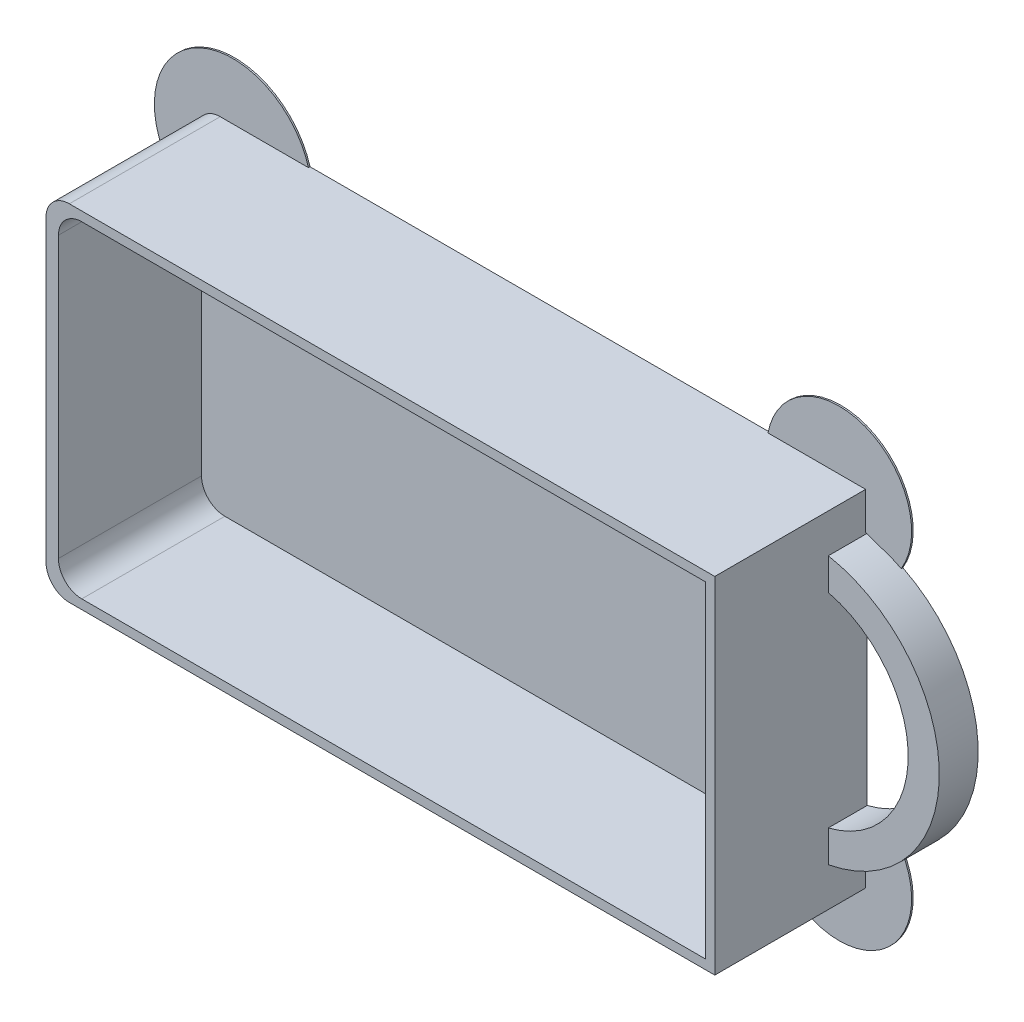
from build123d import *

# Parameters (mm, degrees)
SKETCH_1_W          = 86
SKETCH_1_H          = 44.4
EXTRUDE_1_DEPTH     = 19.6
EXTRUDE_2_DEPTH     = 5
SKETCH_3_W          = 83.2
SKETCH_3_H          = 42
CUT_EXTRUDE_1_DEPTH = 18.4
FILLET_1_R          = 3
EXTRUDE_3_DEPTH     = 0.2


with BuildPart() as part:
    # Эскиз1 → Бобышка-Вытянуть1 (new body)
    with BuildSketch(Plane.XY):
        Rectangle(SKETCH_1_W, SKETCH_1_H)
    extrude(amount=EXTRUDE_1_DEPTH)

    # Эскиз2 → Бобышка-Вытянуть2 (add)
    with BuildSketch(Plane.XY):
        with BuildLine():
            Line((43, 17.2), (43, 13.108775687))
            ThreePointArc((43, 13.108775687), (53.273546839, 0), (43, -13.108775687))
            Line((43, -13.108775687), (43, -17.2))
            ThreePointArc((43, -17.2), (57.273546839, 0), (43, 17.2))
        make_face()
    extrude(amount=EXTRUDE_2_DEPTH)

    # Эскиз3 → Вырез-Вытянуть1 (cut)
    with BuildSketch(Plane.XY.offset(19.6)):
        with Locations((0.2, 0)):
            Rectangle(SKETCH_3_W, SKETCH_3_H)
    extrude(amount=-CUT_EXTRUDE_1_DEPTH, mode=Mode.SUBTRACT)

    # Скругление1
    fillet_1_edges = [part.edges().sort_by_distance(p)[0] for p in [
        (-41.4, -21, 10.4),
        (-41.4, 21, 10.4),
        (-43, -22.2, 9.8),
        (-43, 22.2, 9.8),
    ]]
    fillet(fillet_1_edges, radius=FILLET_1_R)

    # Эскиз4 → Бобышка-Вытянуть3 (add)
    with BuildSketch(Plane(origin=(0, 0, 0), x_dir=(-1, 0, 0), z_dir=(0, 0, -1))):
        with BuildLine():
            Line((-47.582884167, 15.66091474), (-30.44547065, 22.2))
            ThreePointArc((-30.44547065, 22.2), (-42.919306358, 29.16488726), (-47.582884167, 15.66091474))
        make_face()
        with BuildLine():
            Line((-47.582884167, -15.66091474), (-30.44547065, -22.2))
            ThreePointArc((-30.44547065, -22.2), (-42.919306358, -29.16488726), (-47.582884167, -15.66091474))
        make_face()
        with BuildLine():
            Line((43, 10.417706136), (28.64602487, 22.2))
            ThreePointArc((28.64602487, 22.2), (44.771493482, 27.210488681), (43, 10.417706136))
        make_face()
        with BuildLine():
            Line((43, -10.417706136), (28.64602487, -22.2))
            ThreePointArc((28.64602487, -22.2), (44.771493482, -27.210488681), (43, -10.417706136))
        make_face()
    extrude(amount=-EXTRUDE_3_DEPTH)


solid = part.part
